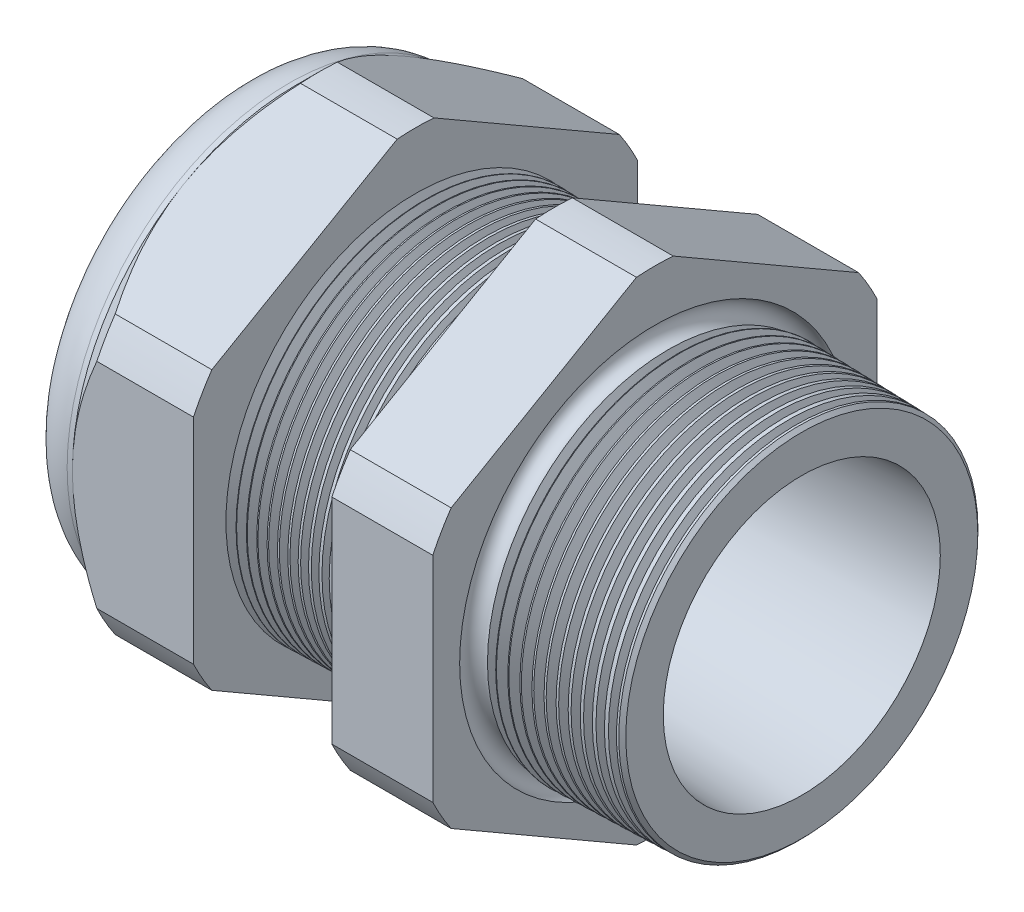
from build123d import *

# Parameters (mm, degrees)
SKETCH12_OUTSIDE_W = 88.514
SKETCH12_OUTSIDE_H = 88.514
CUT_EXTRUDE2_DEPTH = 38.71
FILLET4_R          = 3.81
SKETCH19_OUTSIDE_W = 55.962
SKETCH19_OUTSIDE_H = 59.594
SKETCH19_OUTSIDE_R = 16.51
CUT_EXTRUDE3_DEPTH = 3.99796
CUT_EXTRUDE3_DRAFT = -45
CHAMFER1_SIZE      = 0.260919487
CHAMFER1_SIZE2     = 0.254
SKETCH21_R         = 9.017
PLUG_DEPTH         = 8.89
SKETCH22_R         = 8.763
CUT_EXTRUDE4_DEPTH = 0.508
SKETCH27_R         = 2.54
PLUGHOLES_DEPTH    = 42.402
CIRPATTERN1_COUNT  = 4
CIRPATTERN1_ANGLE  = 216
LPATTERN1_COUNT    = 14
LPATTERN1_PITCH    = 0.762
LPATTERN2_COUNT    = 12
LPATTERN2_PITCH    = 0.889
SKETCH32_R         = 0.889
SKETCH33_R         = 1.905
CUT_EXTRUDE6_DEPTH = 42.402


with BuildPart() as part:
    # Sketch10 → Revolve2 (revolve)
    with BuildSketch(Plane.XY, mode=Mode.PRIVATE) as revolve2_sk:
        Polygon((-38.862, 9.017), (-25.662, 9.017), (3.048, 10.297202192), (3.048, 13.345202192), (-7.874, 13.631204827), (-7.874, 33.02), (-15.374, 33.02), (-15.374, 13.827599239), (-25.662, 14.097), (-25.662, 33.02), (-34.662, 33.02), (-34.662, 16.51), (-38.862, 16.51), align=None)
    revolve(revolve2_sk.sketch.rotate(Axis((0, 0, 0), (-1, 0, 0)), 90), axis=Axis((0, 0, 0), (-1, 0, 0)))  # turned: the seam where the file's is

    # Sketch12 outside → Cut-Extrude2 (cut, through all)
    with BuildSketch(Plane.ZY.offset(34.662)):
        Rectangle(SKETCH12_OUTSIDE_W, SKETCH12_OUTSIDE_H)
        with BuildLine():
            Line((-1.366648898, 18.27507078), (-15.143351102, 10.321088053))
            ThreePointArc((-15.143351102, 10.321088053), (-15.870868152, 9.16305), (-16.51, 7.953982726))
            Line((-16.51, 7.953982726), (-16.51, -7.953982726))
            ThreePointArc((-16.51, -7.953982726), (-15.870868152, -9.16305), (-15.143351102, -10.321088053))
            Line((-15.143351102, -10.321088053), (-1.366648898, -18.27507078))
            ThreePointArc((-1.366648898, -18.27507078), (0, -18.3261), (1.366648898, -18.27507078))
            Line((1.366648898, -18.27507078), (15.143351102, -10.321088053))
            ThreePointArc((15.143351102, -10.321088053), (15.870868152, -9.16305), (16.51, -7.953982726))
            Line((16.51, -7.953982726), (16.51, 7.953982726))
            ThreePointArc((16.51, 7.953982726), (15.870868152, 9.16305), (15.143351102, 10.321088053))
            Line((15.143351102, 10.321088053), (1.366648898, 18.27507078))
            ThreePointArc((1.366648898, 18.27507078), (0, 18.3261), (-1.366648898, 18.27507078))
        make_face(mode=Mode.SUBTRACT)
    extrude(amount=-CUT_EXTRUDE2_DEPTH, mode=Mode.SUBTRACT)

    # Fillet4
    fillet4_edges = [part.edges().sort_by_distance(p)[0] for p in [
        (-38.862, 0, 16.51),
    ]]
    fillet(fillet4_edges, radius=FILLET4_R)


with BuildPart() as cut_extrude3_tool:
    # Sketch19 outside → Cut-Extrude3 (with draft: the straight prism first)
    with BuildSketch(Plane.ZY.offset(34.662)):
        Rectangle(SKETCH19_OUTSIDE_W, SKETCH19_OUTSIDE_H)
        Circle(SKETCH19_OUTSIDE_R, mode=Mode.SUBTRACT)
    extrude(amount=-CUT_EXTRUDE3_DEPTH)
    # Cut-Extrude3: the draft: its side faces are tilted about the plane it starts from
    cut_extrude3_sides = [cut_extrude3_tool.faces().sort_by_distance(p)[0] for p in [
        (-32.66302, -29.797, 0),
        (-32.66302, 0, 27.981),
        (-32.66302, 29.797, 0),
        (-32.66302, 0, -27.981),
        (-32.66302, 0, -16.51),
    ]]
    draft(cut_extrude3_sides, Plane.ZY.offset(34.662), CUT_EXTRUDE3_DRAFT)


with BuildPart() as part_1:
    add(part.part)

    # Cut-Extrude3: cut by cut_extrude3_tool
    add(cut_extrude3_tool.part, mode=Mode.SUBTRACT)

    # Chamfer1
    chamfer1_edges = [part_1.edges().sort_by_distance(p)[0] for p in [
        (3.048, 0, 13.345202192),
    ]]
    chamfer1_side = [part_1.faces().sort_by_distance(p)[0] for p in [
        (3.048, 0, 10.67466151),
    ]]
    chamfer(chamfer1_edges, length=CHAMFER1_SIZE, length2=CHAMFER1_SIZE2, reference=chamfer1_side[0])

    # Sketch29 → Cut-Revolve1 (revolve, cut)
    with BuildSketch(Plane.XY, mode=Mode.PRIVATE) as cut_revolve1_sk:
        Polygon((-25.662, 14.097), (-24.929016419, 14.077806149), (-25.312130572, 13.452620673), align=None)
    cut_revolve1 = revolve(cut_revolve1_sk.sketch.rotate(Axis((0, 0, 0), (-1, 0, 0)), 90), axis=Axis((0, 0, 0), (-1, 0, 0)), mode=Mode.SUBTRACT)  # turned: the seam where the file's is

    # LPattern1: Cut-Revolve1 ×14
    with Locations(*[(i * LPATTERN1_PITCH, 0, 0) for i in range(1, LPATTERN1_COUNT)]):
        add(cut_revolve1, mode=Mode.SUBTRACT)

    # Sketch30 → Cut-Revolve2 (revolve, cut)
    with BuildSketch(Plane.XY, mode=Mode.PRIVATE) as cut_revolve2_sk:
        Polygon((-7.874, 13.631204827), (-6.994419703, 13.608172206), (-7.454156686, 12.857949635), align=None)
    cut_revolve2 = revolve(cut_revolve2_sk.sketch.rotate(Axis((0, 0, 0), (-1, 0, 0)), 270), axis=Axis((0, 0, 0), (-1, 0, 0)), mode=Mode.SUBTRACT)  # turned: the seam where the file's is

    # LPattern2: Cut-Revolve2 ×12
    with Locations(*[(i * LPATTERN2_PITCH, 0, 0) for i in range(1, LPATTERN2_COUNT)]):
        add(cut_revolve2, mode=Mode.SUBTRACT)

    # Sketch32 → Cut-Revolve3 (revolve, cut)
    with BuildSketch(Plane.XY, mode=Mode.PRIVATE) as cut_revolve3_sk:
        with Locations((-7.747, 13.631204827)):
            Circle(SKETCH32_R)
    revolve(cut_revolve3_sk.sketch.rotate(Axis((0, 0, 0), (-1, 0, 0)), 270), axis=Axis((0, 0, 0), (-1, 0, 0)), mode=Mode.SUBTRACT)  # turned: the seam where the file's is


with BuildPart() as body_2:
    # Sketch21 → plug (new body)
    with BuildSketch(Plane.ZY.offset(38.862)):
        Circle(SKETCH21_R)
    extrude(amount=-PLUG_DEPTH)

    # Sketch22 → Cut-Extrude4 (cut)
    with BuildSketch(Plane.ZY.offset(38.862)):
        Circle(SKETCH22_R)
    extrude(amount=-CUT_EXTRUDE4_DEPTH, mode=Mode.SUBTRACT)

    # Sketch27 → plugholes (cut, through all)
    with BuildSketch(Plane.ZY.offset(38.354)):
        with Locations((-6.096, 0)):
            Circle(SKETCH27_R)
    plugholes = extrude(amount=-PLUGHOLES_DEPTH, mode=Mode.SUBTRACT)

    # CirPattern1: plugholes ×4 about axis
    cirpattern1_axis = Axis((0, 0, 0), (-1, 0, 0))
    for i in range(1, CIRPATTERN1_COUNT):
        add(plugholes.rotate(cirpattern1_axis, i * CIRPATTERN1_ANGLE / (CIRPATTERN1_COUNT - 1)), mode=Mode.SUBTRACT)

    # Sketch33 → Cut-Extrude6 (cut, through all)
    with BuildSketch(Plane.ZY.offset(38.354)):
        with Locations((-1.923012756, 5.918424701)):
            Circle(SKETCH33_R)
    extrude(amount=-CUT_EXTRUDE6_DEPTH, mode=Mode.SUBTRACT)


solid = Compound([part_1.part, body_2.part])
